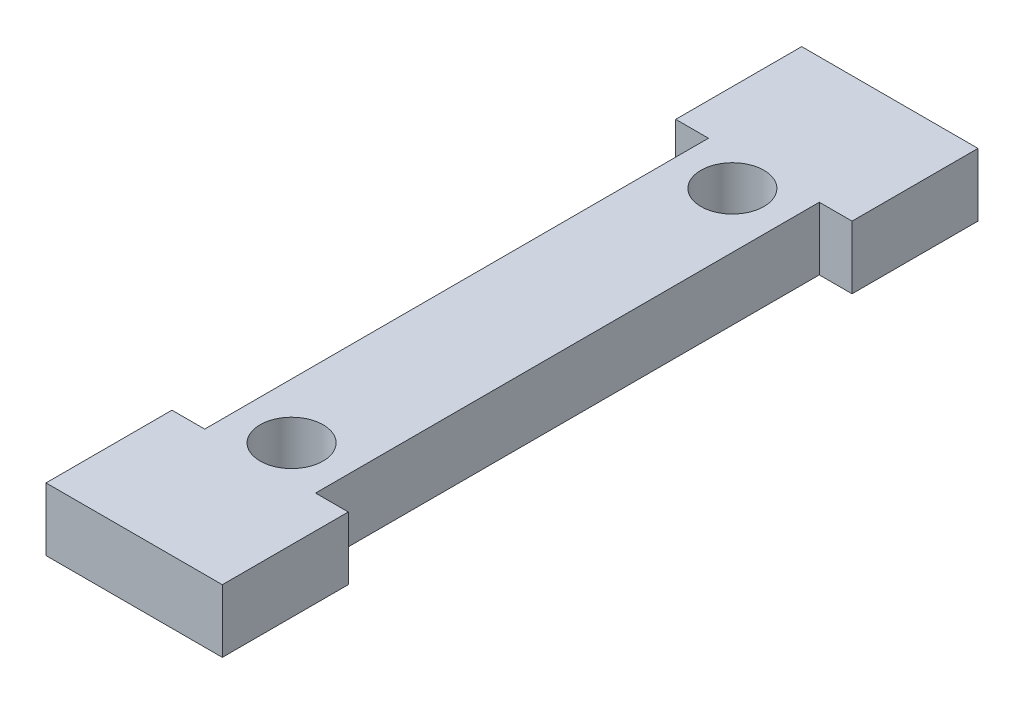
from build123d import *

# Parameters (mm, degrees)
SKETCH1_R           = 3.175
BOSS_EXTRUDE2_DEPTH = 6.35


with BuildPart() as part:
    # Sketch1 → Boss-Extrude2 (new body)
    with BuildSketch(Plane(origin=(0, 0, 0), x_dir=(1, 0, 0), z_dir=(0, 1, 0))):
        Polygon((-3.302, 0), (14.478, 0), (14.478, 12.7), (11.176, 12.7), (11.176, 63.5), (14.478, 63.5), (14.478, 76.2), (-3.302, 76.2), (-3.302, 63.5), (0, 63.5), (0, 12.7), (-3.302, 12.7), align=None)
        with Locations((5.588, 60.325)):
            Circle(SKETCH1_R, mode=Mode.SUBTRACT)
        with Locations((5.588, 15.875)):
            Circle(SKETCH1_R, mode=Mode.SUBTRACT)
    extrude(amount=BOSS_EXTRUDE2_DEPTH)


solid = part.part
